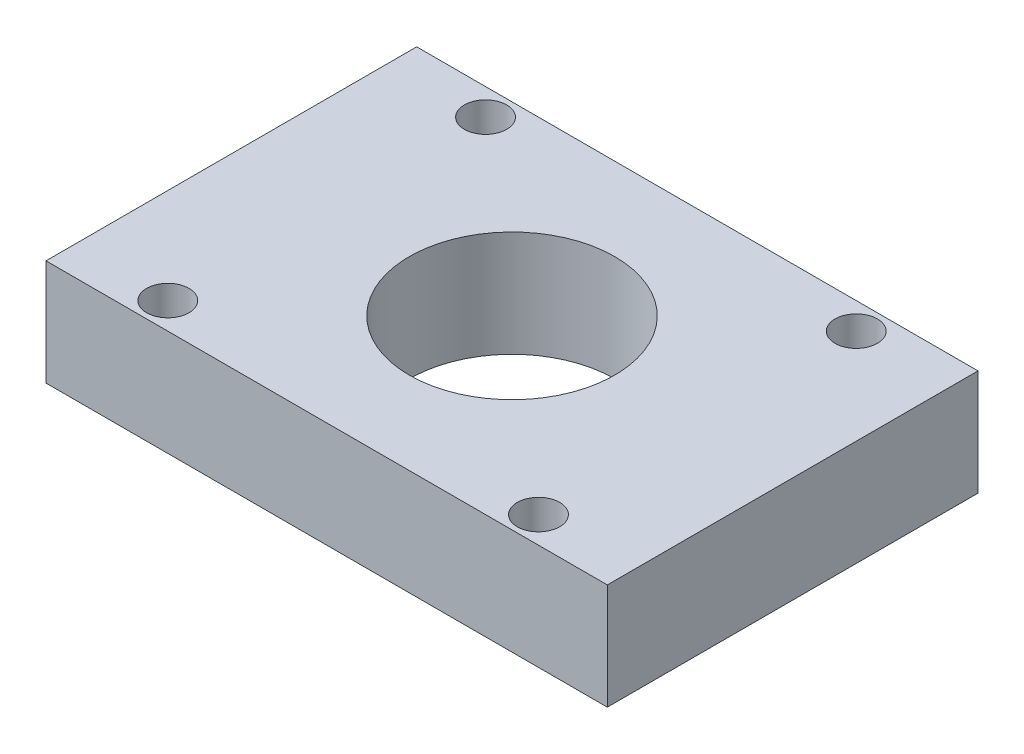
from build123d import *

# Parameters (mm, degrees)
SKETCH1_W           = 53
SKETCH1_H           = 35
BOSS_EXTRUDE1_DEPTH = 10
SKETCH2_R           = 2
SKETCH2_R_2         = 9.699233374
CUT_EXTRUDE1_DEPTH  = 11


with BuildPart() as part:
    # Sketch1 → Boss-Extrude1 (new body)
    with BuildSketch(Plane(origin=(0, 0, 0), x_dir=(1, 0, 0), z_dir=(0, 1, 0))):
        Rectangle(SKETCH1_W, SKETCH1_H)
    extrude(amount=BOSS_EXTRUDE1_DEPTH)

    # Sketch2 → Cut-Extrude1 (cut, through all)
    with BuildSketch(Plane(origin=(0, 10, 0), x_dir=(1, 0, 0), z_dir=(0, 1, 0))):
        with Locations((-17.5, 15)):
            Circle(SKETCH2_R)
        with Locations((17.5, 15)):
            Circle(SKETCH2_R)
        with Locations((-17.5, -15)):
            Circle(SKETCH2_R)
        with Locations((17.5, -15)):
            Circle(SKETCH2_R)
        Circle(SKETCH2_R_2)
    extrude(amount=-CUT_EXTRUDE1_DEPTH, mode=Mode.SUBTRACT)


solid = part.part
